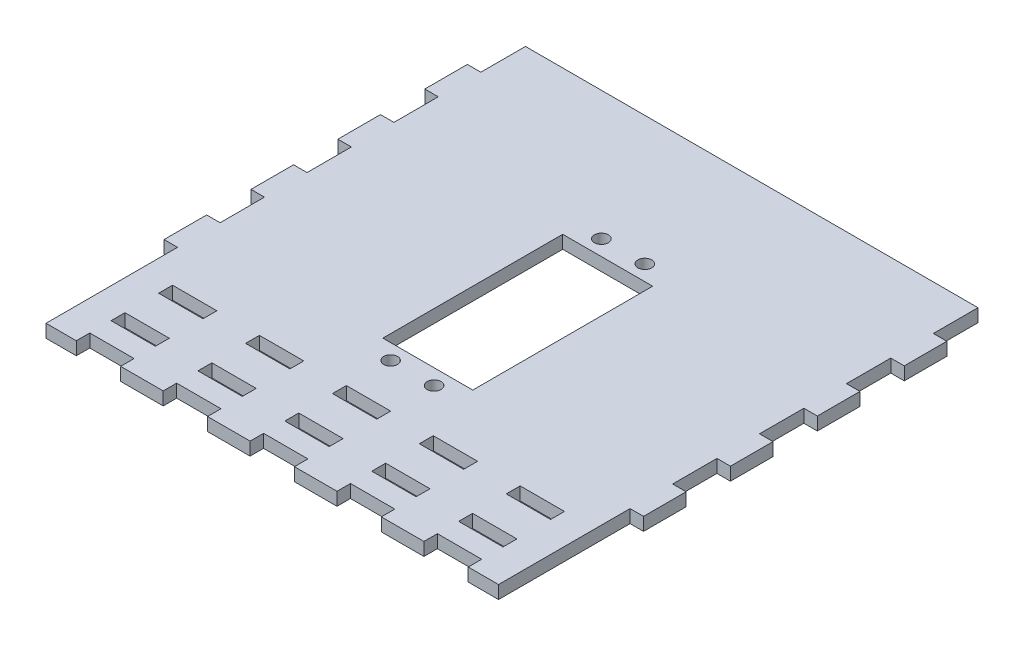
from build123d import *

# Parameters (mm, degrees)
SKETCH1_W           = 110.344434204
SKETCH1_H           = 110.344434204
SKETCH1_R           = 1.6
SKETCH1_W_2         = 20.7
SKETCH1_H_2         = 41.4
BOSS_EXTRUDE1_DEPTH = 3
SKETCH3_W           = 3.2
SKETCH3_H           = 10.2
SKETCH3_H_2         = 10.372217102
SKETCH3_W_2         = 10.2
SKETCH3_H_3         = 3.2
SKETCH3_H_4         = 30.372217102
CUT_EXTRUDE1_DEPTH  = 4


with BuildPart() as part:
    # Sketch1 → Boss-Extrude1 (new body)
    with BuildSketch(Plane(origin=(0, 0, 0), x_dir=(1, 0, 0), z_dir=(0, 1, 0))):
        with Locations((0, -11.670773756)):
            Rectangle(SKETCH1_W, SKETCH1_H)
        with Locations((-5, 13.9)):
            Circle(SKETCH1_R, mode=Mode.SUBTRACT)
        with Locations((5, 13.9)):
            Circle(SKETCH1_R, mode=Mode.SUBTRACT)
        with Locations((5, -34.6)):
            Circle(SKETCH1_R, mode=Mode.SUBTRACT)
        with Locations((-5, -34.6)):
            Circle(SKETCH1_R, mode=Mode.SUBTRACT)
        with Locations((0, -10.35)):
            Rectangle(SKETCH1_W_2, SKETCH1_H_2, mode=Mode.SUBTRACT)
    extrude(amount=BOSS_EXTRUDE1_DEPTH)

    # Sketch3 → Cut-Extrude1 (cut, through all)
    with BuildSketch(Plane(origin=(0, 0, 0), x_dir=(1, 0, 0), z_dir=(0, 1, 0))):
        with Locations((53.672217102, -1.670773756)):
            Rectangle(SKETCH3_W, SKETCH3_H)
        with Locations((53.672217102, 18.329226244)):
            Rectangle(SKETCH3_W, SKETCH3_H)
        with Locations((53.672217102, 38.415334795)):
            Rectangle(SKETCH3_W, SKETCH3_H_2)
        with Locations((40, -46.292990858)):
            Rectangle(SKETCH3_W_2, SKETCH3_H_3)
        with Locations((53.672217102, -21.670773756)):
            Rectangle(SKETCH3_W, SKETCH3_H)
        with Locations((20, -46.292990858)):
            Rectangle(SKETCH3_W_2, SKETCH3_H_3)
        with Locations((0, -46.292990858)):
            Rectangle(SKETCH3_W_2, SKETCH3_H_3)
        with Locations((-20, -46.292990858)):
            Rectangle(SKETCH3_W_2, SKETCH3_H_3)
        with Locations((-40, -46.292990858)):
            Rectangle(SKETCH3_W_2, SKETCH3_H_3)
        with Locations((-53.672217102, 38.415334795)):
            Rectangle(SKETCH3_W, SKETCH3_H_2)
        with Locations((-53.672217102, 18.329226244)):
            Rectangle(SKETCH3_W, SKETCH3_H)
        with Locations((-53.672217102, -1.670773756)):
            Rectangle(SKETCH3_W, SKETCH3_H)
        with Locations((-53.672217102, -21.670773756)):
            Rectangle(SKETCH3_W, SKETCH3_H)
        with Locations((40, -65.342990858)):
            Rectangle(SKETCH3_W_2, SKETCH3_H_3)
        with Locations((53.672217102, -51.756882307)):
            Rectangle(SKETCH3_W, SKETCH3_H_4)
        with Locations((40, -57.242990858)):
            Rectangle(SKETCH3_W_2, SKETCH3_H_3)
        with Locations((20, -65.342990858)):
            Rectangle(SKETCH3_W_2, SKETCH3_H_3)
        with Locations((0, -65.342990858)):
            Rectangle(SKETCH3_W_2, SKETCH3_H_3)
        with Locations((20, -57.242990858)):
            Rectangle(SKETCH3_W_2, SKETCH3_H_3)
        with Locations((0, -57.242990858)):
            Rectangle(SKETCH3_W_2, SKETCH3_H_3)
        with Locations((-40, -65.342990858)):
            Rectangle(SKETCH3_W_2, SKETCH3_H_3)
        with Locations((-40, -57.242990858)):
            Rectangle(SKETCH3_W_2, SKETCH3_H_3)
        with Locations((-20, -57.242990858)):
            Rectangle(SKETCH3_W_2, SKETCH3_H_3)
        with Locations((-20, -65.342990858)):
            Rectangle(SKETCH3_W_2, SKETCH3_H_3)
        with Locations((-53.672217102, -51.756882307)):
            Rectangle(SKETCH3_W, SKETCH3_H_4)
    extrude(amount=CUT_EXTRUDE1_DEPTH, mode=Mode.SUBTRACT)


solid = part.part
